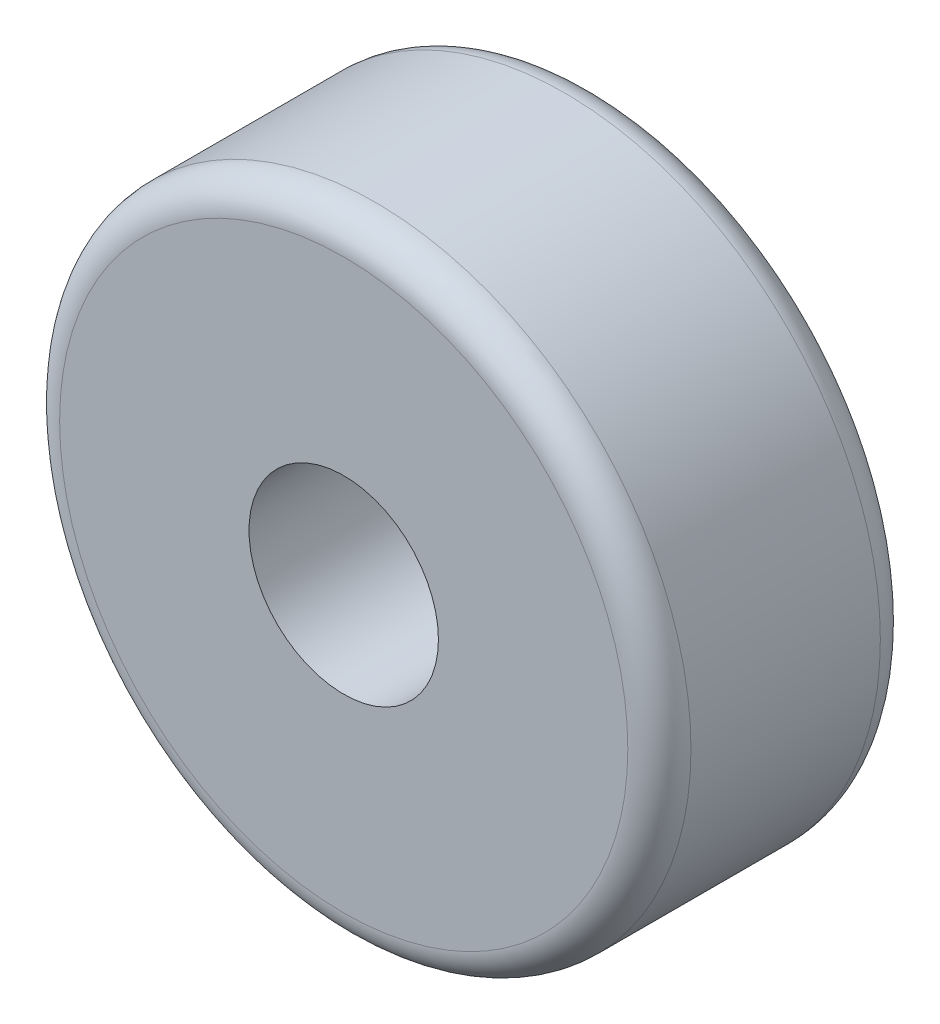
from build123d import *

# Parameters (mm, degrees)
ESQUISSE1_R        = 5
ESQUISSE1_R_2      = 1.5
BOSS_EXTRU_1_DEPTH = 4
CONG_1_R           = 0.5


with BuildPart() as part:
    # Esquisse1 → Boss.-Extru.1 (new body)
    with BuildSketch(Plane.XY):
        Circle(ESQUISSE1_R)
        Circle(ESQUISSE1_R_2, mode=Mode.SUBTRACT)
    extrude(amount=BOSS_EXTRU_1_DEPTH)

    # Congé1
    cong_1_edges = [part.edges().sort_by_distance(p)[0] for p in [
        (-5, 0, 0),
        (-5, 0, 4),
    ]]
    fillet(cong_1_edges, radius=CONG_1_R)


solid = part.part
